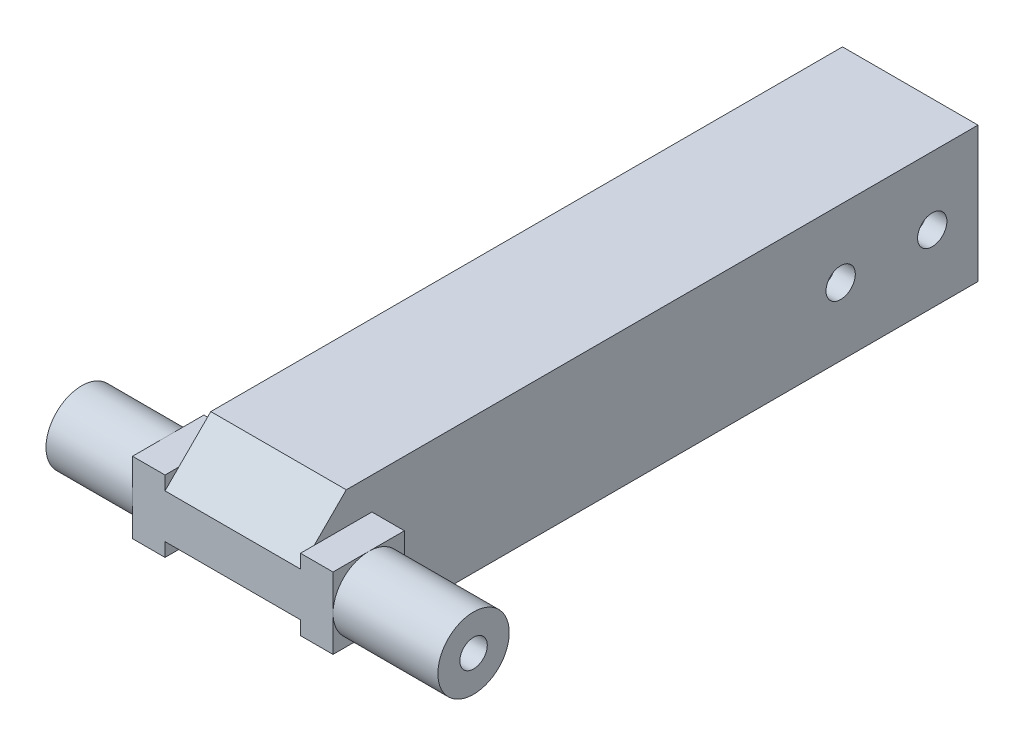
from build123d import *

# Parameters (mm, degrees)
SKETCH_1_W          = 74
SKETCH_1_H          = 14.8
EXTRUDE_1_DEPTH     = 14.8
SKETCH_2_W          = 10.4
SKETCH_2_H          = 10.4
CUT_EXTRUDE_1_DEPTH = 30
SKETCH_3_R          = 3.9
EXTRUDE_2_DEPTH     = 15
SKETCH_4_R          = 3.9
EXTRUDE_3_DEPTH     = 13
CHAMFER_1_SIZE      = 5
SKETCH_8_R          = 1.45
CUT_EXTRUDE_4_DEPTH = 43.8
SKETCH_9_W          = 7.8
SKETCH_9_H          = 7.8
SKETCH_9_R          = 1.5
EXTRUDE_4_DEPTH     = 3.55
SKETCH_10_W         = 7.8
SKETCH_10_H         = 7.8
EXTRUDE_5_DEPTH     = 3.55
SKETCH1_R           = 1.6
CUT_EXTRUDE1_DEPTH  = 30.8
SKETCH2_R           = 1.5
CUT_EXTRUDE2_DEPTH  = 43.8


with BuildPart() as part:
    # Эскиз1 → Бобышка-Вытянуть1 (new body)
    with BuildSketch(Plane(origin=(0, 0, 0), x_dir=(0, 0, -1), z_dir=(1, 0, 0))):
        Rectangle(SKETCH_1_W, SKETCH_1_H)
    extrude(amount=EXTRUDE_1_DEPTH)

    # Эскиз2 → Вырез-Вытянуть1 (cut)
    with BuildSketch(Plane(origin=(0, 0, -37), x_dir=(-1, 0, 0), z_dir=(0, 0, -1))):
        with Locations((-7.4, 0)):
            Rectangle(SKETCH_2_W, SKETCH_2_H)
    extrude(amount=-CUT_EXTRUDE_1_DEPTH, mode=Mode.SUBTRACT)

    # Эскиз3 → Бобышка-Вытянуть2 (add)
    with BuildSketch(Plane(origin=(14.8, 0, 0), x_dir=(0, 0, -1), z_dir=(1, 0, 0))):
        with Locations(Location((-33.1, 0, 0), (0, 0, 180))):  # turned: the seam where the file's is
            Circle(SKETCH_3_R)
    extrude(amount=EXTRUDE_2_DEPTH)

    # Эскиз4 → Бобышка-Вытянуть3 (add)
    with BuildSketch(Plane.ZY):
        with Locations((33.1, 0)):
            Circle(SKETCH_4_R)
    extrude(amount=EXTRUDE_3_DEPTH)

    # Фаска1
    chamfer_1_edges = [part.edges().sort_by_distance(p)[0] for p in [
        (7.4, 7.4, 37),
        (7.4, -7.4, 37),
    ]]
    chamfer(chamfer_1_edges, length=CHAMFER_1_SIZE)

    # Эскиз8 → Вырез-Вытянуть4 (cut, through all)
    with BuildSketch(Plane(origin=(29.8, 0, 0), x_dir=(0, 0, -1), z_dir=(1, 0, 0))):
        with Locations((-33.1, 0)):
            Circle(SKETCH_8_R)
    extrude(amount=-CUT_EXTRUDE_4_DEPTH, mode=Mode.SUBTRACT)

    # Эскиз9 → Бобышка-Вытянуть4 (add)
    with BuildSketch(Plane.ZY):
        with Locations((33.1, 0)):
            Rectangle(SKETCH_9_W, SKETCH_9_H)
        with Locations((33.1, 0)):
            Circle(SKETCH_9_R, mode=Mode.SUBTRACT)
    extrude(amount=EXTRUDE_4_DEPTH)

    # Эскиз10 → Бобышка-Вытянуть5 (add)
    with BuildSketch(Plane(origin=(14.8, 0, 0), x_dir=(0, 0, -1), z_dir=(1, 0, 0))):
        with Locations((-33.1, 0)):
            Rectangle(SKETCH_10_W, SKETCH_10_H)
    extrude(amount=EXTRUDE_5_DEPTH)

    # Sketch1 → Cut-Extrude1 (cut, through all)
    with BuildSketch(Plane.ZY):
        with Locations((-32, 0)):
            Circle(SKETCH1_R)
        with Locations((-22, 0)):
            Circle(SKETCH1_R)
    extrude(amount=-CUT_EXTRUDE1_DEPTH, mode=Mode.SUBTRACT)

    # Sketch2 → Cut-Extrude2 (cut, through all)
    with BuildSketch(Plane(origin=(29.8, 0, 0), x_dir=(0, 0, -1), z_dir=(1, 0, 0))):
        with Locations((-33.1, 0)):
            Circle(SKETCH2_R)
    extrude(amount=-CUT_EXTRUDE2_DEPTH, mode=Mode.SUBTRACT)


solid = part.part
